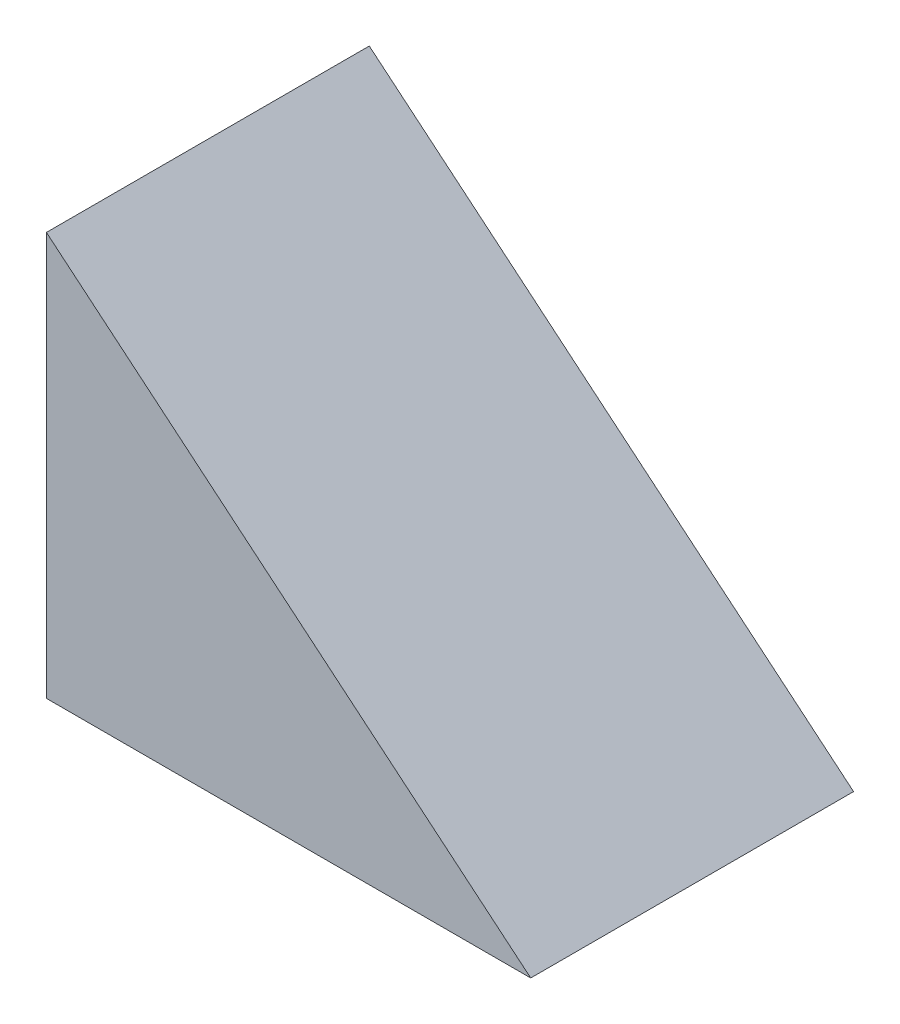
from build123d import *

# Parameters (mm, degrees)
BOSS_EXTRUDE1_DEPTH = 20


with BuildPart() as part:
    # Sketch1 → Boss-Extrude1 (new body)
    with BuildSketch(Plane.XY):
        Polygon((0, 0), (0, 25), (30, 0), align=None)
    extrude(amount=BOSS_EXTRUDE1_DEPTH)


solid = part.part
